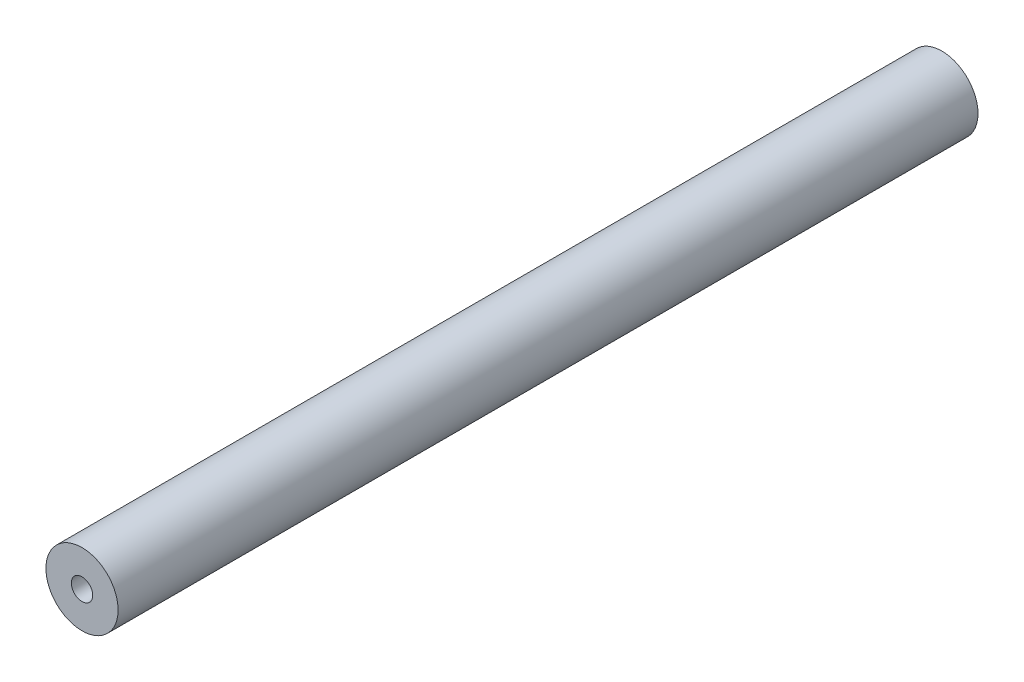
from build123d import *

# Parameters (mm, degrees)
SKETCH1_R                  = 6.4
BOSS_EXTRUDE1_DEPTH        = 152.53
F_10_24_TAPPED_HOLE1_D     = 3.7973
F_10_24_TAPPED_HOLE1_DEPTH = 12.83
F_10_24_TAPPED_HOLE1_TIP   = 1.140824014
F_10_24_TAPPED_HOLE2_D     = 3.7973
F_10_24_TAPPED_HOLE2_DEPTH = 12.83
F_10_24_TAPPED_HOLE2_TIP   = 1.140824014


with BuildPart() as part:
    # Sketch1 → Boss-Extrude1 (new body)
    with BuildSketch(Plane.XY):
        Circle(SKETCH1_R)
    extrude(amount=BOSS_EXTRUDE1_DEPTH)

    # #10-24 Tapped Hole1
    with Locations(Plane(origin=(0, 0, 0), x_dir=(-1, 0, 0), z_dir=(0, 0, -1))):
        with Locations((0, 0)):
            Hole(F_10_24_TAPPED_HOLE1_D / 2, depth=F_10_24_TAPPED_HOLE1_DEPTH)
            with Locations((0, 0, -(F_10_24_TAPPED_HOLE1_DEPTH + F_10_24_TAPPED_HOLE1_TIP / 2))):  # 118° drill point
                Cone(0, F_10_24_TAPPED_HOLE1_D / 2, F_10_24_TAPPED_HOLE1_TIP, mode=Mode.SUBTRACT)

    # #10-24 Tapped Hole2
    with Locations(Plane.XY.offset(152.53)):
        with Locations((0, 0)):
            Hole(F_10_24_TAPPED_HOLE2_D / 2, depth=F_10_24_TAPPED_HOLE2_DEPTH)
            with Locations((0, 0, -(F_10_24_TAPPED_HOLE2_DEPTH + F_10_24_TAPPED_HOLE2_TIP / 2))):  # 118° drill point
                Cone(0, F_10_24_TAPPED_HOLE2_D / 2, F_10_24_TAPPED_HOLE2_TIP, mode=Mode.SUBTRACT)


solid = part.part
